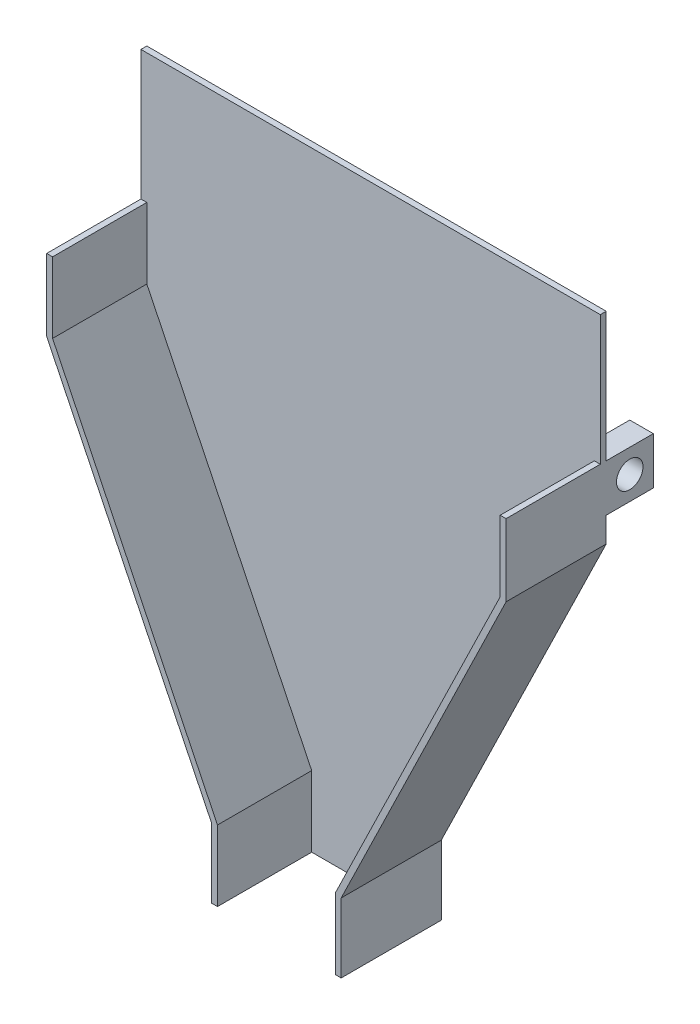
from build123d import *

# Parameters (mm, degrees)
EXTRUDE_THIN1_DEPTH        = 101.6
EXTRUDE_THIN1_DEPTH_BACK   = 6.35
EXTRUDE_THIN1_2_DEPTH      = 101.6
EXTRUDE_THIN1_2_DEPTH_BACK = 6.35
BOSS_EXTRUDE1_DEPTH        = 6.35
SKETCH2_W                  = 25.4
SKETCH2_H                  = 50.8
BOSS_EXTRUDE2_DEPTH        = 50.8
SKETCH3_R                  = 14.2875
CUT_EXTRUDE1_DEPTH         = 496.3
SKETCH4_W                  = 495.3
SKETCH4_H                  = 6.35
BOSS_EXTRUDE3_DEPTH        = 139.7


with BuildPart() as part:
    # Sketch1 → Extrude-Thin1 (new body, two sides)
    with BuildSketch(Plane.XY) as extrude_thin1_sk:
        Polygon((0, 0), (0, 76.2), (177.8, 441.642362076), (177.8, 517.842362076), (184.15, 517.842362076), (184.15, 440.179589293), (6.35, 74.737227217), (6.35, 0), align=None)
    extrude(amount=EXTRUDE_THIN1_DEPTH)
    extrude(extrude_thin1_sk.sketch, amount=-EXTRUDE_THIN1_DEPTH_BACK)



with BuildPart() as body_2:
    # Sketch1 → Extrude-Thin1 2 (new body, two sides)
    with BuildSketch(Plane.XY) as extrude_thin1_2_sk:
        Polygon((-304.8, 517.842362076), (-304.8, 441.642362076), (-127, 76.2), (-127, 0), (-133.35, 0), (-133.35, 74.737227217), (-311.15, 440.179589293), (-311.15, 517.842362076), align=None)
    extrude(amount=EXTRUDE_THIN1_2_DEPTH)
    extrude(extrude_thin1_2_sk.sketch, amount=-EXTRUDE_THIN1_2_DEPTH_BACK)

    # Sketch1_3 → Boss-Extrude1 (add)
    with BuildSketch(Plane.XY):
        Polygon((-127, 0), (0, 0), (0, 76.2), (177.8, 441.642362076), (177.8, 517.842362076), (-304.8, 517.842362076), (-304.8, 441.642362076), (-127, 76.2), align=None)
    extrude(amount=-BOSS_EXTRUDE1_DEPTH)


with BuildPart() as part_1:
    add(part.part)

    add(body_2.part)  # Boss-Extrude2 merges body 2
    # Sketch2 → Boss-Extrude2 (add)
    with BuildSketch(Plane(origin=(0, 0, -6.35), x_dir=(-1, 0, 0), z_dir=(0, 0, -1))):
        with Locations((-171.45, 492.442362076)):
            Rectangle(SKETCH2_W, SKETCH2_H)
        with Locations((298.45, 492.442362076)):
            Rectangle(SKETCH2_W, SKETCH2_H)
    extrude(amount=BOSS_EXTRUDE2_DEPTH)

    # Sketch3 → Cut-Extrude1 (cut, through all)
    with BuildSketch(Plane(origin=(184.15, 0, 0), x_dir=(0, 0, -1), z_dir=(1, 0, 0))):
        with Locations((31.75, 492.442362076)):
            Circle(SKETCH3_R)
    extrude(amount=-CUT_EXTRUDE1_DEPTH, mode=Mode.SUBTRACT)

    # Sketch4 → Boss-Extrude3 (add)
    with BuildSketch(Plane(origin=(0, 517.842362076, 0), x_dir=(1, 0, 0), z_dir=(0, 1, 0))):
        with Locations((-63.5, 3.175)):
            Rectangle(SKETCH4_W, SKETCH4_H)
    extrude(amount=BOSS_EXTRUDE3_DEPTH)


solid = part_1.part
